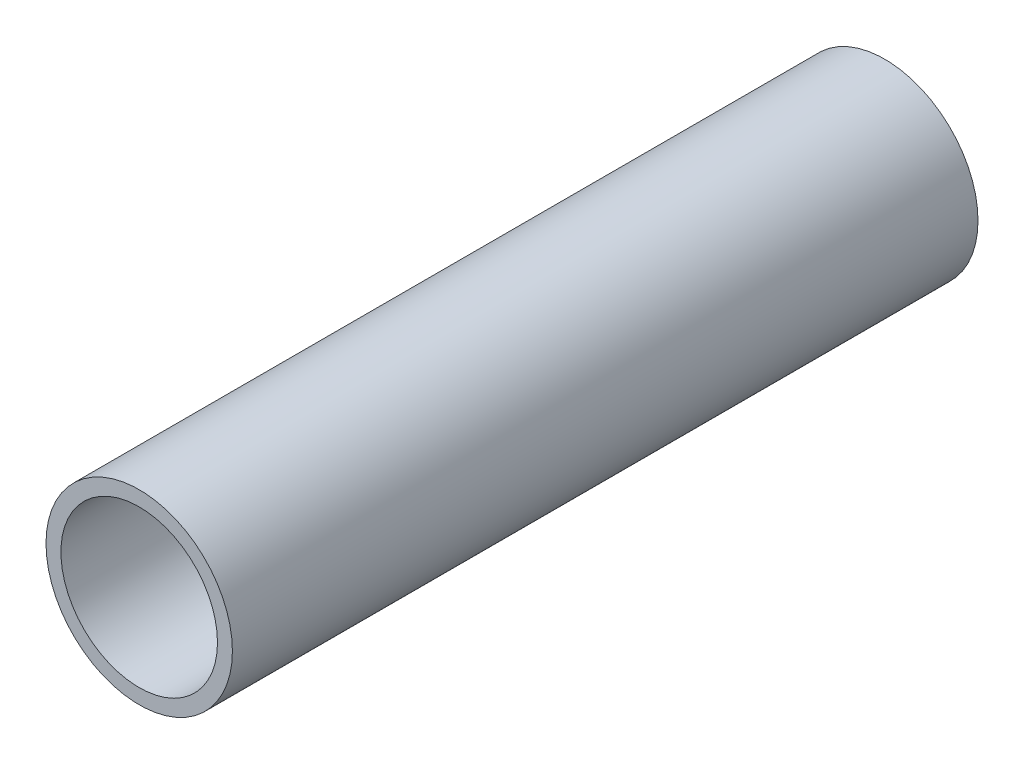
from build123d import *

# Parameters (mm, degrees)
CROQUIS1_R              = 6.25
CROQUIS1_R_2            = 5.25
SALIENTE_EXTRUIR1_DEPTH = 25


with BuildPart() as part:
    # Croquis1 → Saliente-Extruir1 (new body, symmetric)
    with BuildSketch(Plane.XY):
        Circle(CROQUIS1_R)
        Circle(CROQUIS1_R_2, mode=Mode.SUBTRACT)
    extrude(amount=SALIENTE_EXTRUIR1_DEPTH, both=True)


solid = part.part
